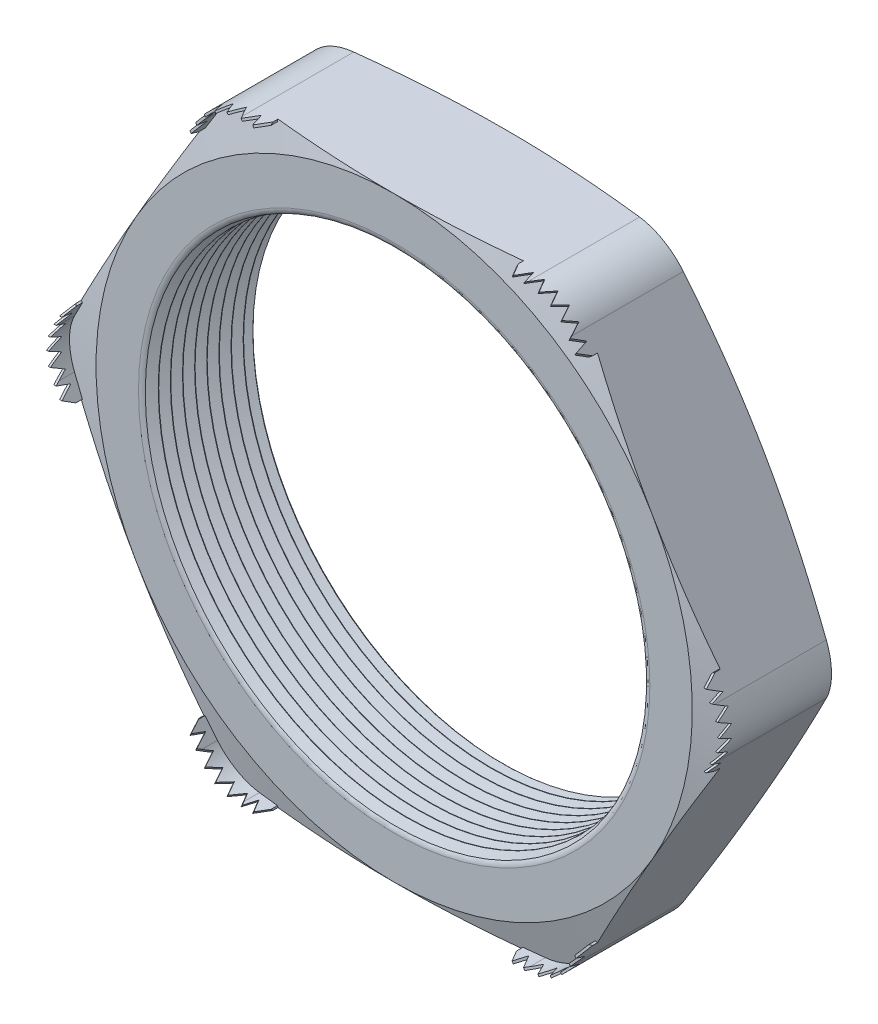
from build123d import *

# Parameters (mm, degrees)
SKETCH1_R          = 6.223
EXTRUDE1_DEPTH     = 2.794
FILLET1_R          = 1.27
FILLET3_R          = 0.2032
LPATTERN1_COUNT    = 9
LPATTERN1_PITCH    = 0.3048
SKETCH4_OUTSIDE_W  = 51.784
SKETCH4_OUTSIDE_H  = 49.858
SKETCH4_OUTSIDE_R  = 7.493
CUT_EXTRUDE1_DEPTH = 3.794
CUT_EXTRUDE1_DRAFT = -75
SKETCH5_OUTSIDE_W  = 51.784
SKETCH5_OUTSIDE_H  = 49.858
SKETCH5_OUTSIDE_R  = 7.493
CUT_EXTRUDE2_DEPTH = 3.7940001
CUT_EXTRUDE2_DRAFT = -75
EXTRUDE2_START     = -0.257955
EXTRUDE2_DEPTH     = 1.019955
CUT_EXTRUDE4_DEPTH = 3.72941959
CIRPATTERN1_COUNT  = 6
CIRPATTERN2_COUNT  = 6


with BuildPart() as part:
    # Sketch1 → Extrude1 (new body)
    with BuildSketch(Plane.XY):
        Polygon((-8.652171134, 0), (-4.326085567, -7.493), (4.326085567, -7.493), (8.652171134, 0), (4.326085567, 7.493), (-4.326085567, 7.493), align=None)
        Circle(SKETCH1_R, mode=Mode.SUBTRACT)
    extrude(amount=EXTRUDE1_DEPTH)

    # Fillet1
    fillet1_edges = [part.edges().sort_by_distance(p)[0] for p in [
        (8.652171134, 0, 1.397),
        (4.326085567, -7.493, 1.397),
        (-4.326085567, -7.493, 1.397),
        (-8.652171134, 0, 1.397),
        (-4.326085567, 7.493, 1.397),
        (4.326085567, 7.493, 1.397),
    ]]
    fillet(fillet1_edges, radius=FILLET1_R)

    # Fillet3
    fillet3_edges = [part.edges().sort_by_distance(p)[0] for p in [
        (-6.223, 0, 0),
        (-6.223, 0, 2.794),
    ]]
    fillet(fillet3_edges, radius=FILLET3_R)

    # Sketch3 → Cut-Revolve1 (revolve, cut)
    with BuildSketch(Plane(origin=(0, 0, 0), x_dir=(1, 0, 0), z_dir=(0, 1, 0))):
        Polygon((-6.223, -2.794), (-6.223, -2.500706063), (-6.477, -2.647353032), align=None)
    cut_revolve1 = revolve(axis=Axis((0, 0, 2.794), (0, 0, -1)), mode=Mode.SUBTRACT)

    # LPattern1: Cut-Revolve1 ×9
    with Locations(*[(0, 0, -i * LPATTERN1_PITCH) for i in range(1, LPATTERN1_COUNT)]):
        add(cut_revolve1, mode=Mode.SUBTRACT)


with BuildPart() as cut_extrude1_tool:
    # Sketch4 outside → Cut-Extrude1 (with draft: the straight prism first)
    with BuildSketch(Plane(origin=(0, 0, 0), x_dir=(-1, 0, 0), z_dir=(0, 0, -1))):
        Rectangle(SKETCH4_OUTSIDE_W, SKETCH4_OUTSIDE_H)
        Circle(SKETCH4_OUTSIDE_R, mode=Mode.SUBTRACT)
    extrude(amount=-CUT_EXTRUDE1_DEPTH)
    # Cut-Extrude1: the draft: its side faces are tilted about the plane it starts from
    cut_extrude1_sides = [cut_extrude1_tool.faces().sort_by_distance(p)[0] for p in [
        (0, -24.929, 1.897),
        (-25.892, 0, 1.897),
        (0, 24.929, 1.897),
        (25.892, 0, 1.897),
        (7.493, 0, 1.897),
    ]]
    draft(cut_extrude1_sides, Plane(origin=(0, 0, 0), x_dir=(-1, 0, 0), z_dir=(0, 0, -1)), CUT_EXTRUDE1_DRAFT)


with BuildPart() as part_1:
    add(part.part)

    # Cut-Extrude1: cut by cut_extrude1_tool
    add(cut_extrude1_tool.part, mode=Mode.SUBTRACT)


with BuildPart() as cut_extrude2_tool:
    # Sketch5 outside → Cut-Extrude2 (with draft: the straight prism first)
    with BuildSketch(Plane.XY.offset(2.794)):
        Rectangle(SKETCH5_OUTSIDE_W, SKETCH5_OUTSIDE_H)
        Circle(SKETCH5_OUTSIDE_R, mode=Mode.SUBTRACT)
    extrude(amount=-CUT_EXTRUDE2_DEPTH)
    # Cut-Extrude2: the draft: its side faces are tilted about the plane it starts from
    cut_extrude2_sides = [cut_extrude2_tool.faces().sort_by_distance(p)[0] for p in [
        (0, -24.929, 0.89699995),
        (25.892, 0, 0.89699995),
        (0, 24.929, 0.89699995),
        (-25.892, 0, 0.89699995),
        (-7.493, 0, 0.89699995),
    ]]
    draft(cut_extrude2_sides, Plane.XY.offset(2.794), CUT_EXTRUDE2_DRAFT)


with BuildPart() as part_2:
    add(part_1.part)

    # Cut-Extrude2: cut by cut_extrude2_tool
    add(cut_extrude2_tool.part, mode=Mode.SUBTRACT)

    # Sketch2 → Extrude2 (add)
    with BuildSketch(Plane.XY.offset(2.794).offset(EXTRUDE2_START)):
        with BuildLine():
            Line((-3.592850725, 7.493), (-3.084850725, 7.493))
            Line((-3.084850725, 7.493), (-3.084850725, 7.4422))
            Line((-3.084850725, 7.4422), (-3.592850725, 7.4422))
            ThreePointArc((-3.592850725, 7.4422), (-4.202450725, 7.278858172), (-4.648708897, 6.8326))
            Line((-4.648708897, 6.8326), (-4.902708897, 6.392659095))
            Line((-4.902708897, 6.392659095), (-4.946702988, 6.418059095))
            Line((-4.946702988, 6.418059095), (-4.692702988, 6.858))
            ThreePointArc((-4.692702988, 6.858), (-4.227850725, 7.322852263), (-3.592850725, 7.493))
        make_face()
    extrude2 = extrude(amount=EXTRUDE2_DEPTH)

    # Sketch7 → Cut-Extrude4 (cut, through all)
    with BuildSketch(Plane(origin=(-3.993779811, 6.917429547, 0), x_dir=(0.866025404, 0.5, 0), z_dir=(0.5, -0.866025404, 0))):
        Polygon((-1.074940905, 2.7559), (-0.909840905, 3.07594), (-0.744740905, 2.7559), (-0.6604, 3.07594), (-0.4953, 2.7559), (-0.3302, 3.07594), (-0.1651, 2.7559), (0, 3.07594), (0.1651, 2.7559), (0.3302, 3.07594), (0.4953, 2.7559), (0.6604, 3.07594), (0.8255, 2.7559), (0.909840905, 3.07594), (1.074940905, 2.7559), (1.074940905, 3.556), (-1.074940905, 3.556), align=None)
    cut_extrude4 = extrude(amount=-CUT_EXTRUDE4_DEPTH, mode=Mode.SUBTRACT)

    # CirPattern1: Extrude2 ×6 about axis
    cirpattern1_axis = Axis((0, 0, 0), (0, 0, 1))
    for i in range(1, CIRPATTERN1_COUNT):
        add(extrude2.rotate(cirpattern1_axis, i * 360 / CIRPATTERN1_COUNT))

    # CirPattern2: Cut-Extrude4 ×6 about axis
    cirpattern2_axis = Axis((0, 0, 0), (0, 0, 1))
    for i in range(1, CIRPATTERN2_COUNT):
        add(cut_extrude4.rotate(cirpattern2_axis, i * 360 / CIRPATTERN2_COUNT), mode=Mode.SUBTRACT)


solid = part_2.part
